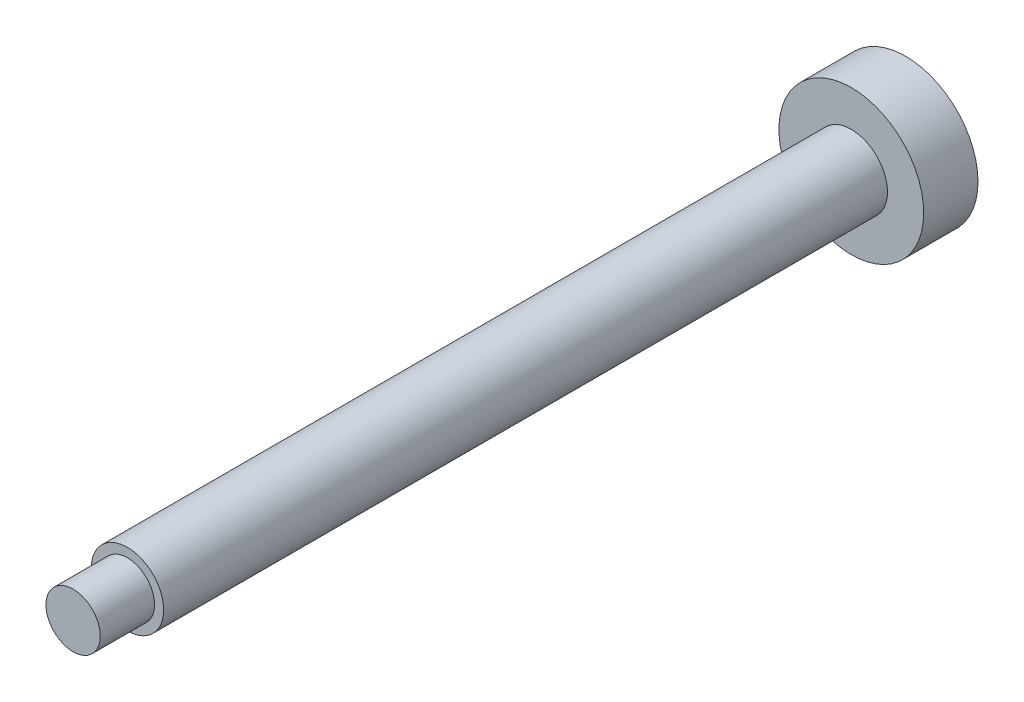
from build123d import *

# Parameters (mm, degrees)
SKETCH1_R           = 2
BOSS_EXTRUDE1_DEPTH = 40
SKETCH3_R           = 1.5
BOSS_EXTRUDE2_DEPTH = 43
SKETCH4_R           = 4
BOSS_EXTRUDE3_DEPTH = 3


with BuildPart() as part:
    # Sketch1 → Boss-Extrude1 (new body)
    with BuildSketch(Plane.XY):
        Circle(SKETCH1_R)
    extrude(amount=BOSS_EXTRUDE1_DEPTH)

    # Sketch3 → Boss-Extrude2 (add)
    with BuildSketch(Plane.XY):
        Circle(SKETCH3_R)
    extrude(amount=BOSS_EXTRUDE2_DEPTH)

    # Sketch4 → Boss-Extrude3 (add)
    with BuildSketch(Plane.XY):
        Circle(SKETCH4_R)
    extrude(amount=-BOSS_EXTRUDE3_DEPTH)


solid = part.part
